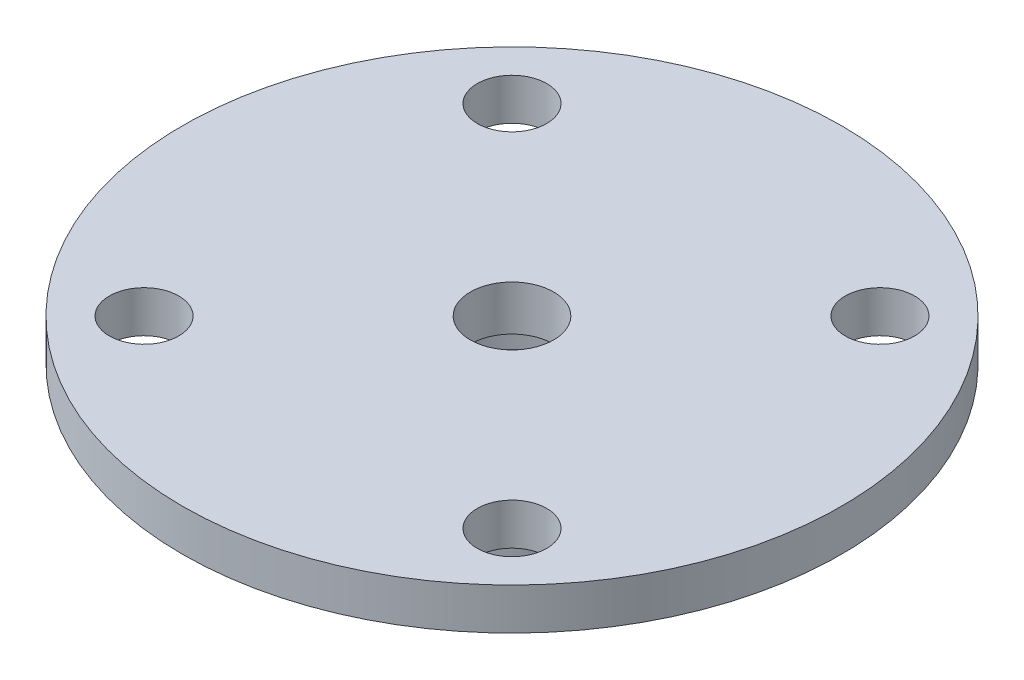
from build123d import *

# Parameters (mm, degrees)
CROQUIS1_R              = 9.5
CROQUIS1_R_2            = 1
SALIENTE_EXTRUIR1_DEPTH = 1.2
CROQUIS2_R              = 4.5
SALIENTE_EXTRUIR2_DEPTH = 2
SKETCH1_R               = 1.2
CUT_EXTRUDE2_DEPTH      = 5
CROQUIS3_R              = 3.35
CUT_EXTRUDE3_DEPTH      = 1.9


with BuildPart() as part:
    # Croquis1 → Saliente-Extruir1 (new body)
    with BuildSketch(Plane(origin=(0, 0, 0), x_dir=(1, 0, 0), z_dir=(0, 1, 0))):
        with Locations((-19.93721465, -8.386058239)):
            Circle(CROQUIS1_R)
        with Locations((-14.633913791, -3.08275738)):
            Circle(CROQUIS1_R_2, mode=Mode.SUBTRACT)
        with Locations((-14.633913791, -13.689359098)):
            Circle(CROQUIS1_R_2, mode=Mode.SUBTRACT)
        with Locations((-25.240515509, -13.689359098)):
            Circle(CROQUIS1_R_2, mode=Mode.SUBTRACT)
        with Locations((-25.240515509, -3.08275738)):
            Circle(CROQUIS1_R_2, mode=Mode.SUBTRACT)
    extrude(amount=SALIENTE_EXTRUIR1_DEPTH)

    # Croquis2 → Saliente-Extruir2 (add)
    with BuildSketch(Plane(origin=(0, 0, 0), x_dir=(-1, 0, 0), z_dir=(0, -1, 0))):
        with Locations((19.93721465, -8.386058239)):
            Circle(CROQUIS2_R)
    extrude(amount=SALIENTE_EXTRUIR2_DEPTH)

    # Sketch1 → Cut-Extrude2 (cut)
    with BuildSketch(Plane(origin=(0, 1.2, 0), x_dir=(1, 0, 0), z_dir=(0, 1, 0))):
        with Locations((-19.93721465, -8.386058239)):
            Circle(SKETCH1_R)
    extrude(amount=-CUT_EXTRUDE2_DEPTH, mode=Mode.SUBTRACT)

    # Croquis3 → Cut-Extrude3 (cut)
    with BuildSketch(Plane(origin=(0, -2, 0), x_dir=(-1, 0, 0), z_dir=(0, -1, 0))):
        with Locations((19.93721465, -8.386058239)):
            Circle(CROQUIS3_R)
    extrude(amount=-CUT_EXTRUDE3_DEPTH, mode=Mode.SUBTRACT)


solid = part.part
